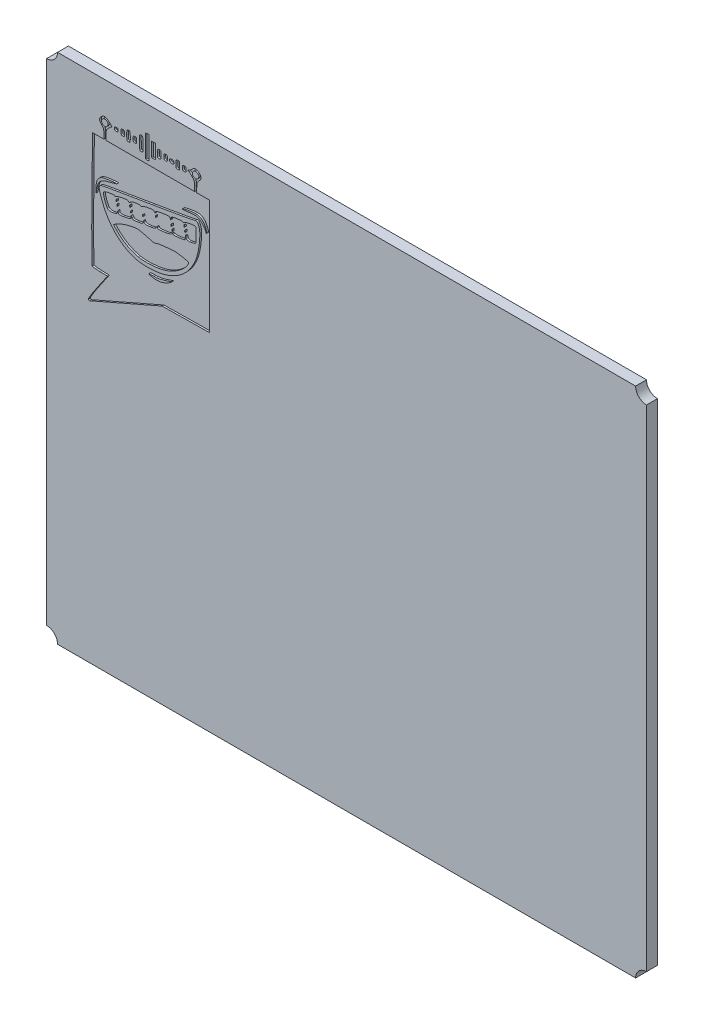
from build123d import *

# Parameters (mm, degrees)
ESQUISSE1_W             = 165
ESQUISSE1_H             = 141
BOSS_EXTRU_1_DEPTH      = 3
ESQUISSE2_R             = 3
ENL_V_MAT_EXTRU_1_DEPTH = 3
ENL_V_MAT_EXTRU_2_DEPTH = 0.5


with BuildPart() as part:
    # Esquisse1 → Boss.-Extru.1 (new body)
    with BuildSketch(Plane.XY):
        with Locations((82.5, 70.5)):
            Rectangle(ESQUISSE1_W, ESQUISSE1_H)
    extrude(amount=BOSS_EXTRU_1_DEPTH)

    # Esquisse2 → Enlèv. mat.-Extru.1 (cut)
    with BuildSketch(Plane.XY.offset(3)):
        with Locations((0, 141)):
            Circle(ESQUISSE2_R)
        with Locations((165, 141)):
            Circle(ESQUISSE2_R)
        with Locations((165, 0)):
            Circle(ESQUISSE2_R)
        Circle(ESQUISSE2_R)
    extrude(amount=-ENL_V_MAT_EXTRU_1_DEPTH, mode=Mode.SUBTRACT)

    # Esquisse4 → Enlèv. mat.-Extru.2 (cut)
    with BuildSketch(Plane(origin=(-49.029714864, 27.03507642, 3), x_dir=(1, 0, 0), z_dir=(0, 0, 1))):
        with BuildLine():
            Line((70.966404243, 63.607118888), (80.794741203, 67.905286568))
            Line((80.794741203, 67.905286568), (87.281438923, 68.003564248))
            Line((87.281438923, 68.003564248), (93.768141723, 68.101841928))
            Line((93.768141723, 68.101841928), (93.818464203, 83.876318888))
            Line((93.818464203, 83.876318888), (93.868771443, 99.650800928))
            Line((93.868771443, 99.650800928), (92.098503203, 99.650800928))
            Line((92.098503203, 99.650800928), (90.328229883, 99.650800928))
            Line((90.328229883, 99.650800928), (90.328229883, 100.913363808))
            add(Edge.make_bspline(
                [(90.328229883, 100.913363808), (90.328229883, 102.054123528), (90.385110643, 102.232817608), (90.917931523, 102.765628328)],
                knots=[0, 0, 0, 0, 1, 1, 1, 1], degree=3))
            add(Edge.make_bspline(
                [(90.917931523, 102.765628328), (91.633794963, 103.481496848), (91.664782963, 104.032549848), (91.025160163, 104.672187888)],
                knots=[0, 0, 0, 0, 1, 1, 1, 1], degree=3))
            add(Edge.make_bspline(
                [(91.025160163, 104.672187888), (90.366157163, 105.331190888), (89.632589923, 105.293248368), (88.952271243, 104.564974488)],
                knots=[0, 0, 0, 0, 1, 1, 1, 1], degree=3))
            add(Edge.make_bspline(
                [(88.952271243, 104.564974488), (88.649305123, 104.240636808), (88.304220723, 103.975272848), (88.185424923, 103.975272848)],
                knots=[0, 0, 0, 0, 1, 1, 1, 1], degree=3))
            add(Edge.make_bspline(
                [(88.185424923, 103.975272848), (88.066634203, 103.975272848), (87.969438563, 103.886809728), (87.969438563, 103.778707328)],
                knots=[0, 0, 0, 0, 1, 1, 1, 1], degree=3))
            add(Edge.make_bspline(
                [(87.969438563, 103.778707328), (87.969438563, 103.670589688), (88.063835123, 103.582141808), (88.179207003, 103.582141808)],
                knots=[0, 0, 0, 0, 1, 1, 1, 1], degree=3))
            add(Edge.make_bspline(
                [(88.179207003, 103.582141808), (88.294568723, 103.582141808), (88.692627363, 103.260176488), (89.063756923, 102.866659368)],
                knots=[0, 0, 0, 0, 1, 1, 1, 1], degree=3))
            add(Edge.make_bspline(
                [(89.063756923, 102.866659368), (89.686697003, 102.206152688), (89.738538403, 102.055129368), (89.738538403, 100.900994008)],
                knots=[0, 0, 0, 0, 1, 1, 1, 1], degree=3))
            Line((89.738538403, 100.900994008), (89.738538403, 99.650806008))
            Line((89.738538403, 99.650806008), (77.551405043, 99.650806008))
            Line((77.551405043, 99.650806008), (65.364271683, 99.650806008))
            Line((65.364271683, 99.650806008), (65.364271683, 100.900994008))
            add(Edge.make_bspline(
                [(65.364271683, 100.900994008), (65.364271683, 102.055129368), (65.416108003, 102.206152688), (66.039053163, 102.866659368)],
                knots=[0, 0, 0, 0, 1, 1, 1, 1], degree=3))
            add(Edge.make_bspline(
                [(66.039053163, 102.866659368), (66.410187803, 103.260176488), (66.818904283, 103.582141808), (66.947311443, 103.582141808)],
                knots=[0, 0, 0, 0, 1, 1, 1, 1], degree=3))
            add(Edge.make_bspline(
                [(66.947311443, 103.582141808), (67.075728763, 103.582141808), (66.816196643, 103.935958728), (66.370584123, 104.368408968)],
                knots=[0, 0, 0, 0, 1, 1, 1, 1], degree=3))
            add(Edge.make_bspline(
                [(66.370584123, 104.368408968), (65.421629963, 105.289336768), (64.779832923, 105.374365808), (64.077660083, 104.672192968)],
                knots=[0, 0, 0, 0, 1, 1, 1, 1], degree=3))
            add(Edge.make_bspline(
                [(64.077660083, 104.672192968), (63.438022043, 104.032554928), (63.469010043, 103.481496848), (64.184878563, 102.765633408)],
                knots=[0, 0, 0, 0, 1, 1, 1, 1], degree=3))
            add(Edge.make_bspline(
                [(64.184878563, 102.765633408), (64.717689283, 102.232822688), (64.774575123, 102.054128608), (64.774575123, 100.913368888)],
                knots=[0, 0, 0, 0, 1, 1, 1, 1], degree=3))
            Line((64.774575123, 100.913368888), (64.774575123, 99.650806008))
            Line((64.774575123, 99.650806008), (63.234054963, 99.650806008))
            Line((63.234054963, 99.650806008), (61.693524643, 99.650806008))
            Line((61.693524643, 99.650806008), (61.563496963, 91.247581768))
            add(Edge.make_bspline(
                [(61.563496963, 91.247581768), (61.389644123, 80.013491968), (61.403314403, 68.157965768), (61.590471763, 67.863488328)],
                knots=[0, 0, 0, 0, 1, 1, 1, 1], degree=3))
            add(Edge.make_bspline(
                [(61.590471763, 67.863488328), (61.688937403, 67.708528008), (62.449408323, 67.605353208), (63.763726243, 67.568634968)],
                knots=[0, 0, 0, 0, 1, 1, 1, 1], degree=3))
            Line((63.763726243, 67.568634968), (65.785505283, 67.512155528))
            Line((65.785505283, 67.512155528), (63.103615803, 63.612173488))
            add(Edge.make_bspline(
                [(63.103615803, 63.612173488), (61.440723523, 61.194002048), (60.465099363, 59.599171608), (60.535873923, 59.414737128)],
                knots=[0, 0, 0, 0, 1, 1, 1, 1], degree=3))
            add(Edge.make_bspline(
                [(60.535873923, 59.414737128), (60.598652563, 59.251135728), (60.759840963, 59.160412008), (60.894064723, 59.213127168)],
                knots=[0, 0, 0, 0, 1, 1, 1, 1], degree=3))
            add(Edge.make_bspline(
                [(60.894064723, 59.213127168), (61.028298643, 59.265827088), (65.560872763, 61.243135808), (70.966404243, 63.607118888)],
                knots=[0, 0, 0, 0, 1, 1, 1, 1], degree=3))
        make_face()
        with BuildLine():
            Line((62.636850163, 87.029225968), (62.661351003, 85.792855568))
            Line((62.661351003, 85.792855568), (62.806862523, 86.783287928))
            add(Edge.make_bspline(
                [(62.806862523, 86.783287928), (62.886903003, 87.328026488), (63.095228723, 88.049970688), (63.269833403, 88.387607808)],
                knots=[0, 0, 0, 0, 1, 1, 1, 1], degree=3))
            add(Edge.make_bspline(
                [(63.269833403, 88.387607808), (63.769095803, 89.353046568), (64.433636003, 89.741585288), (66.392174123, 90.213151528)],
                knots=[0, 0, 0, 0, 1, 1, 1, 1], degree=3))
            add(Edge.make_bspline(
                [(66.392174123, 90.213151528), (67.394437803, 90.454471848), (68.258698203, 90.697778448), (68.312754483, 90.753826088)],
                knots=[0, 0, 0, 0, 1, 1, 1, 1], degree=3))
            add(Edge.make_bspline(
                [(68.312754483, 90.753826088), (68.560602603, 91.010818208), (64.977378883, 90.537565408), (64.246438003, 90.216768488)],
                knots=[0, 0, 0, 0, 1, 1, 1, 1], degree=3))
            add(Edge.make_bspline(
                [(64.246438003, 90.216768488), (63.119323163, 89.722098408), (62.603682843, 88.700967608), (62.636850163, 87.029225968)],
                knots=[0, 0, 0, 0, 1, 1, 1, 1], degree=3))
        make_face(mode=Mode.SUBTRACT)
        with BuildLine():
            add(Edge.make_bspline(
                [(81.004768723, 73.602648808), (81.537924883, 73.763095528), (82.372187883, 74.170719808), (82.858689323, 74.508458528)],
                knots=[0, 0, 0, 0, 1, 1, 1, 1], degree=3))
            add(Edge.make_bspline(
                [(82.858689323, 74.508458528), (83.345190763, 74.846197248), (83.566328243, 75.057550648), (83.350108203, 74.978135008)],
                knots=[0, 0, 0, 0, 1, 1, 1, 1], degree=3))
            add(Edge.make_bspline(
                [(83.350108203, 74.978135008), (81.077712443, 74.143506248), (79.876724243, 73.870984568), (78.435939723, 73.863008968)],
                knots=[0, 0, 0, 0, 1, 1, 1, 1], degree=3))
            add(Edge.make_bspline(
                [(78.435939723, 73.863008968), (76.917583603, 73.854540608), (76.887108683, 73.845457568), (77.551389803, 73.597543408)],
                knots=[0, 0, 0, 0, 1, 1, 1, 1], degree=3))
            add(Edge.make_bspline(
                [(77.551389803, 73.597543408), (78.485119203, 73.249065568), (79.836673523, 73.251051848), (81.004768723, 73.602648808)],
                knots=[0, 0, 0, 0, 1, 1, 1, 1], degree=3))
        make_face(mode=Mode.SUBTRACT)
        with BuildLine():
            add(Edge.make_bspline(
                [(81.145952083, 75.652901248), (85.643372603, 76.820905008), (88.809071123, 79.785806368), (90.298232483, 84.224664648)],
                knots=[0, 0, 0, 0, 1, 1, 1, 1], degree=3))
            add(Edge.make_bspline(
                [(90.298232483, 84.224664648), (90.920883003, 86.080642648), (91.351905763, 89.685319208), (91.119246843, 91.090879008)],
                knots=[0, 0, 0, 0, 1, 1, 1, 1], degree=3))
            add(Edge.make_bspline(
                [(91.119246843, 91.090879008), (90.892998883, 92.457719048), (90.389311803, 93.116727128), (89.813534443, 92.799216968)],
                knots=[0, 0, 0, 0, 1, 1, 1, 1], degree=3))
            add(Edge.make_bspline(
                [(89.813534443, 92.799216968), (89.610116003, 92.687040408), (84.578650323, 91.783506528), (78.632510323, 90.791357128)],
                knots=[0, 0, 0, 0, 1, 1, 1, 1], degree=3))
            add(Edge.make_bspline(
                [(78.632510323, 90.791357128), (63.330849283, 88.238194848), (63.964000163, 88.358341928), (63.666444243, 87.951408528)],
                knots=[0, 0, 0, 0, 1, 1, 1, 1], degree=3))
            add(Edge.make_bspline(
                [(63.666444243, 87.951408528), (63.382878643, 87.563611488), (63.434598123, 87.211791008), (64.041536203, 85.399719448)],
                knots=[0, 0, 0, 0, 1, 1, 1, 1], degree=3))
            add(Edge.make_bspline(
                [(64.041536203, 85.399719448), (65.833490963, 80.049681888), (69.587011523, 76.321810248), (74.138986163, 75.371276208)],
                knots=[0, 0, 0, 0, 1, 1, 1, 1], degree=3))
            add(Edge.make_bspline(
                [(74.138986163, 75.371276208), (75.910854603, 75.001279488), (79.135984043, 75.130905848), (81.145952083, 75.652901248)],
                knots=[0, 0, 0, 0, 1, 1, 1, 1], degree=3))
        make_face(mode=Mode.SUBTRACT)
        with BuildLine():
            add(Edge.make_bspline(
                [(92.687011043, 92.672714808), (92.012564843, 94.065930208), (91.307775803, 94.540072008), (89.911263483, 94.540072008)],
                knots=[0, 0, 0, 0, 1, 1, 1, 1], degree=3))
            add(Edge.make_bspline(
                [(89.911263483, 94.540072008), (88.690488683, 94.540072008), (85.834512683, 93.922862168), (86.458453523, 93.793875888)],
                knots=[0, 0, 0, 0, 1, 1, 1, 1], degree=3))
            add(Edge.make_bspline(
                [(86.458453523, 93.793875888), (86.654480563, 93.753347648), (87.557318483, 93.818996488), (88.464758883, 93.939758248)],
                knots=[0, 0, 0, 0, 1, 1, 1, 1], degree=3))
            add(Edge.make_bspline(
                [(88.464758883, 93.939758248), (89.813443003, 94.119234648), (90.235524963, 94.108815568), (90.776702443, 93.882699688)],
                knots=[0, 0, 0, 0, 1, 1, 1, 1], degree=3))
            add(Edge.make_bspline(
                [(90.776702443, 93.882699688), (91.522974763, 93.570889288), (92.633213843, 92.333309848), (92.832085683, 91.591573968)],
                knots=[0, 0, 0, 0, 1, 1, 1, 1], degree=3))
            add(Edge.make_bspline(
                [(92.832085683, 91.591573968), (92.934503563, 91.209568128), (92.980198163, 91.177772408), (93.037302443, 91.448759928)],
                knots=[0, 0, 0, 0, 1, 1, 1, 1], degree=3))
            add(Edge.make_bspline(
                [(93.037302443, 91.448759928), (93.077718923, 91.640494368), (92.920071283, 92.191273048), (92.687011043, 92.672714808)],
                knots=[0, 0, 0, 0, 1, 1, 1, 1], degree=3))
        make_face(mode=Mode.SUBTRACT)
        with BuildLine():
            add(Edge.make_bspline(
                [(64.528845363, 103.008178008), (63.829136323, 103.415726088), (64.228185563, 104.564974488), (65.069403083, 104.564974488)],
                knots=[0, 0, 0, 0, 1, 1, 1, 1], degree=3))
            add(Edge.make_bspline(
                [(65.069403083, 104.564974488), (65.897178923, 104.564974488), (66.238778443, 103.698478888), (65.645063603, 103.104764048)],
                knots=[0, 0, 0, 0, 1, 1, 1, 1], degree=3))
            add(Edge.make_bspline(
                [(65.645063603, 103.104764048), (65.289702363, 102.749397728), (65.014097123, 102.725552208), (64.528845363, 103.008178008)],
                knots=[0, 0, 0, 0, 1, 1, 1, 1], degree=3))
        make_face(mode=Mode.SUBTRACT)
        with BuildLine():
            add(Edge.make_bspline(
                [(89.492813723, 103.008178008), (88.793104683, 103.415726088), (89.192153923, 104.564974488), (90.033376523, 104.564974488)],
                knots=[0, 0, 0, 0, 1, 1, 1, 1], degree=3))
            add(Edge.make_bspline(
                [(90.033376523, 104.564974488), (90.861147283, 104.564974488), (91.202746803, 103.698478888), (90.609031963, 103.104764048)],
                knots=[0, 0, 0, 0, 1, 1, 1, 1], degree=3))
            add(Edge.make_bspline(
                [(90.609031963, 103.104764048), (90.253670723, 102.749397728), (89.978065483, 102.725552208), (89.492813723, 103.008178008)],
                knots=[0, 0, 0, 0, 1, 1, 1, 1], degree=3))
        make_face(mode=Mode.SUBTRACT)
        with BuildLine():
            Line((68.312759563, 79.690607168), (67.428209643, 80.603808288))
            Line((67.428209643, 80.603808288), (67.919623443, 80.981475808))
            add(Edge.make_bspline(
                [(67.919623443, 80.981475808), (68.659586403, 81.550156408), (70.673654003, 82.309342088), (72.374229723, 82.660608848)],
                knots=[0, 0, 0, 0, 1, 1, 1, 1], degree=3))
            add(Edge.make_bspline(
                [(72.374229723, 82.660608848), (73.744544483, 82.943656288), (74.031671163, 82.944834848), (75.376438603, 82.672973568)],
                knots=[0, 0, 0, 0, 1, 1, 1, 1], degree=3))
            add(Edge.make_bspline(
                [(75.376438603, 82.672973568), (76.194272883, 82.507634808), (77.241713003, 82.238394808), (77.704074283, 82.074661328)],
                knots=[0, 0, 0, 0, 1, 1, 1, 1], degree=3))
            add(Edge.make_bspline(
                [(77.704074283, 82.074661328), (78.349320643, 81.846173088), (78.669172683, 81.826462688), (79.080043083, 81.989876128)],
                knots=[0, 0, 0, 0, 1, 1, 1, 1], degree=3))
            add(Edge.make_bspline(
                [(79.080043083, 81.989876128), (79.374464643, 82.106959968), (79.880706963, 82.237002888), (80.205044643, 82.278826528)],
                knots=[0, 0, 0, 0, 1, 1, 1, 1], degree=3))
            add(Edge.make_bspline(
                [(80.205044643, 82.278826528), (83.154685683, 82.659191528), (83.977955563, 82.723133488), (84.781906203, 82.634294448)],
                knots=[0, 0, 0, 0, 1, 1, 1, 1], degree=3))
            add(Edge.make_bspline(
                [(84.781906203, 82.634294448), (86.343930003, 82.461686208), (87.974991003, 82.109835248), (88.092201843, 81.920193768)],
                knots=[0, 0, 0, 0, 1, 1, 1, 1], degree=3))
            add(Edge.make_bspline(
                [(88.092201843, 81.920193768), (88.153385363, 81.821184568), (87.957043363, 81.384589048), (87.655880643, 80.950000128)],
                knots=[0, 0, 0, 0, 1, 1, 1, 1], degree=3))
            add(Edge.make_bspline(
                [(87.655880643, 80.950000128), (86.327008523, 79.032437288), (83.716863883, 77.353431248), (80.952094203, 76.637710048)],
                knots=[0, 0, 0, 0, 1, 1, 1, 1], degree=3))
            add(Edge.make_bspline(
                [(80.952094203, 76.637710048), (78.951945803, 76.119925968), (75.858672843, 75.981003208), (74.308038403, 76.339315928)],
                knots=[0, 0, 0, 0, 1, 1, 1, 1], degree=3))
            add(Edge.make_bspline(
                [(74.308038403, 76.339315928), (71.884441523, 76.899335128), (69.991537003, 77.957453408), (68.312759563, 79.690607168)],
                knots=[0, 0, 0, 0, 1, 1, 1, 1], degree=3))
        make_face()
        with BuildLine():
            Line((87.204400723, 87.567137008), (87.084858163, 86.786061608))
            Line((87.084858163, 86.786061608), (85.622473483, 86.542033648))
            add(Edge.make_bspline(
                [(85.622473483, 86.542033648), (84.545650643, 86.362338808), (84.090553763, 86.355704328), (83.896365683, 86.516872408)],
                knots=[0, 0, 0, 0, 1, 1, 1, 1], degree=3))
            add(Edge.make_bspline(
                [(83.896365683, 86.516872408), (83.698108523, 86.681413608), (83.573191323, 86.660326528), (83.393085003, 86.431909408)],
                knots=[0, 0, 0, 0, 1, 1, 1, 1], degree=3))
            add(Edge.make_bspline(
                [(83.393085003, 86.431909408), (83.261325043, 86.264807888), (82.571323883, 86.030543688), (81.859737803, 85.911331328)],
                knots=[0, 0, 0, 0, 1, 1, 1, 1], degree=3))
            add(Edge.make_bspline(
                [(81.859737803, 85.911331328), (80.002225643, 85.600120368), (79.517613963, 85.626409368), (79.514144323, 86.038575168)],
                knots=[0, 0, 0, 0, 1, 1, 1, 1], degree=3))
            add(Edge.make_bspline(
                [(79.514144323, 86.038575168), (79.512396803, 86.291792848), (79.446148523, 86.253896048), (79.264538523, 85.894978808)],
                knots=[0, 0, 0, 0, 1, 1, 1, 1], degree=3))
            add(Edge.make_bspline(
                [(79.264538523, 85.894978808), (79.058762963, 85.488274008), (78.790213843, 85.369569648), (77.645760963, 85.179399848)],
                knots=[0, 0, 0, 0, 1, 1, 1, 1], degree=3))
            add(Edge.make_bspline(
                [(77.645760963, 85.179399848), (76.211610923, 84.941091968), (75.804276203, 85.046898208), (75.759013403, 85.669508088)],
                knots=[0, 0, 0, 0, 1, 1, 1, 1], degree=3))
            add(Edge.make_bspline(
                [(75.759013403, 85.669508088), (75.746247363, 85.845464048), (75.679348843, 85.725997688), (75.610398003, 85.404006968)],
                knots=[0, 0, 0, 0, 1, 1, 1, 1], degree=3))
            add(Edge.make_bspline(
                [(75.610398003, 85.404006968), (75.492577563, 84.853776928), (75.404703723, 84.805400088), (74.148953123, 84.599426408)],
                knots=[0, 0, 0, 0, 1, 1, 1, 1], degree=3))
            add(Edge.make_bspline(
                [(74.148953123, 84.599426408), (72.890713323, 84.393041248), (72.796306603, 84.403927688), (72.528473763, 84.786314528)],
                knots=[0, 0, 0, 0, 1, 1, 1, 1], degree=3))
            Line((72.528473763, 84.786314528), (72.244069963, 85.192353848))
            Line((72.244069963, 85.192353848), (72.244069963, 84.759233048))
            add(Edge.make_bspline(
                [(72.244069963, 84.759233048), (72.244069963, 84.302205768), (72.271222563, 84.313529088), (70.232095323, 83.919869728)],
                knots=[0, 0, 0, 0, 1, 1, 1, 1], degree=3))
            add(Edge.make_bspline(
                [(70.232095323, 83.919869728), (68.973169723, 83.676832368), (68.716441763, 83.752961248), (68.682614043, 84.379355728)],
                knots=[0, 0, 0, 0, 1, 1, 1, 1], degree=3))
            add(Edge.make_bspline(
                [(68.682614043, 84.379355728), (68.665357283, 84.698725168), (68.626835643, 84.658049608), (68.533541443, 84.221977328)],
                knots=[0, 0, 0, 0, 1, 1, 1, 1], degree=3))
            add(Edge.make_bspline(
                [(68.533541443, 84.221977328), (68.437117963, 83.771325448), (68.270326323, 83.604523648), (67.819674443, 83.508110328)],
                knots=[0, 0, 0, 0, 1, 1, 1, 1], degree=3))
            add(Edge.make_bspline(
                [(67.819674443, 83.508110328), (66.575297963, 83.241872608), (65.974339043, 83.317823688), (65.683742723, 83.778056448)],
                knots=[0, 0, 0, 0, 1, 1, 1, 1], degree=3))
            add(Edge.make_bspline(
                [(65.683742723, 83.778056448), (65.104810683, 84.694976128), (64.501062843, 86.708073448), (64.707077163, 87.034671728)],
                knots=[0, 0, 0, 0, 1, 1, 1, 1], degree=3))
            add(Edge.make_bspline(
                [(64.707077163, 87.034671728), (64.950927323, 87.421254648), (67.522494443, 87.939434968), (67.803342243, 87.658582088)],
                knots=[0, 0, 0, 0, 1, 1, 1, 1], degree=3))
            add(Edge.make_bspline(
                [(67.803342243, 87.658582088), (67.925033643, 87.536900848), (68.102935243, 87.565272648), (68.300247523, 87.737799608)],
                knots=[0, 0, 0, 0, 1, 1, 1, 1], degree=3))
            add(Edge.make_bspline(
                [(68.300247523, 87.737799608), (68.469299763, 87.885617448), (69.223664523, 88.111438688), (69.976632283, 88.239632488)],
                knots=[0, 0, 0, 0, 1, 1, 1, 1], degree=3))
            add(Edge.make_bspline(
                [(69.976632283, 88.239632488), (71.148964203, 88.439225688), (71.376472003, 88.430569368), (71.560149563, 88.179363368)],
                knots=[0, 0, 0, 0, 1, 1, 1, 1], degree=3))
            add(Edge.make_bspline(
                [(71.560149563, 88.179363368), (71.747012283, 87.923819048), (71.803227563, 87.931794648), (71.996501243, 88.241273328)],
                knots=[0, 0, 0, 0, 1, 1, 1, 1], degree=3))
            add(Edge.make_bspline(
                [(71.996501243, 88.241273328), (72.261870283, 88.666189928), (74.571685323, 89.146031488), (74.877867083, 88.839849728)],
                knots=[0, 0, 0, 0, 1, 1, 1, 1], degree=3))
            add(Edge.make_bspline(
                [(74.877867083, 88.839849728), (75.002042603, 88.715669128), (75.178369403, 88.747149888), (75.379847283, 88.929486328)],
                knots=[0, 0, 0, 0, 1, 1, 1, 1], degree=3))
            add(Edge.make_bspline(
                [(75.379847283, 88.929486328), (75.550657203, 89.084070728), (76.305794123, 89.308850568), (77.057928763, 89.429007808)],
                knots=[0, 0, 0, 0, 1, 1, 1, 1], degree=3))
            add(Edge.make_bspline(
                [(77.057928763, 89.429007808), (78.256503963, 89.620478088), (78.454334403, 89.607966048), (78.659266683, 89.327702448)],
                knots=[0, 0, 0, 0, 1, 1, 1, 1], degree=3))
            add(Edge.make_bspline(
                [(78.659266683, 89.327702448), (78.872484443, 89.036115528), (78.899103643, 89.039168608), (78.961338723, 89.362337888)],
                knots=[0, 0, 0, 0, 1, 1, 1, 1], degree=3))
            add(Edge.make_bspline(
                [(78.961338723, 89.362337888), (79.015090203, 89.641392448), (79.405310403, 89.786172448), (80.796722403, 90.043276328)],
                knots=[0, 0, 0, 0, 1, 1, 1, 1], degree=3))
            add(Edge.make_bspline(
                [(80.796722403, 90.043276328), (82.621397443, 90.380441008), (83.030601603, 90.310088088), (83.078516163, 89.650978408)],
                knots=[0, 0, 0, 0, 1, 1, 1, 1], degree=3))
            add(Edge.make_bspline(
                [(83.078516163, 89.650978408), (83.091282203, 89.475017368), (83.158058803, 89.593772528), (83.226857243, 89.914894568)],
                knots=[0, 0, 0, 0, 1, 1, 1, 1], degree=3))
            add(Edge.make_bspline(
                [(83.226857243, 89.914894568), (83.345592083, 90.469081928), (83.426557123, 90.511230688), (84.821037443, 90.744712568)],
                knots=[0, 0, 0, 0, 1, 1, 1, 1], degree=3))
            add(Edge.make_bspline(
                [(84.821037443, 90.744712568), (85.757393203, 90.901486448), (86.358423243, 90.922405888), (86.478428083, 90.802401048)],
                knots=[0, 0, 0, 0, 1, 1, 1, 1], degree=3))
            add(Edge.make_bspline(
                [(86.478428083, 90.802401048), (86.598438003, 90.682386048), (86.778183643, 90.711362368), (86.974078603, 90.882263728)],
                knots=[0, 0, 0, 0, 1, 1, 1, 1], degree=3))
            add(Edge.make_bspline(
                [(86.974078603, 90.882263728), (87.406742203, 91.259758528), (89.762729363, 91.646016328), (90.026015603, 91.382618328)],
                knots=[0, 0, 0, 0, 1, 1, 1, 1], degree=3))
            add(Edge.make_bspline(
                [(90.026015603, 91.382618328), (90.268219843, 91.140312488), (90.235768803, 87.685704208), (89.988957003, 87.438907648)],
                knots=[0, 0, 0, 0, 1, 1, 1, 1], degree=3))
            add(Edge.make_bspline(
                [(89.988957003, 87.438907648), (89.896379083, 87.346314488), (89.382206883, 87.188656688), (88.846383723, 87.088550208)],
                knots=[0, 0, 0, 0, 1, 1, 1, 1], degree=3))
            add(Edge.make_bspline(
                [(88.846383723, 87.088550208), (87.728702443, 86.879746968), (87.394260643, 87.046050928), (87.351827403, 87.831718648)],
                knots=[0, 0, 0, 0, 1, 1, 1, 1], degree=3))
            add(Edge.make_bspline(
                [(87.351827403, 87.831718648), (87.332660563, 88.186505848), (87.286513843, 88.103666288), (87.204400723, 87.567137008)],
                knots=[0, 0, 0, 0, 1, 1, 1, 1], degree=3))
        make_face()
        with BuildLine():
            add(Edge.make_bspline(
                [(68.442939643, 85.940277168), (68.388385523, 86.075420408), (68.343803443, 85.964833888), (68.343803443, 85.694567728)],
                knots=[0, 0, 0, 0, 1, 1, 1, 1], degree=3))
            add(Edge.make_bspline(
                [(68.343803443, 85.694567728), (68.343803443, 85.424291408), (68.388410923, 85.313720128), (68.442939643, 85.448863368)],
                knots=[0, 0, 0, 0, 1, 1, 1, 1], degree=3))
            add(Edge.make_bspline(
                [(68.442939643, 85.448863368), (68.497498843, 85.584006608), (68.497498843, 85.805139008), (68.442939643, 85.940277168)],
                knots=[0, 0, 0, 0, 1, 1, 1, 1], degree=3))
        make_face(mode=Mode.SUBTRACT)
        with BuildLine():
            add(Edge.make_bspline(
                [(72.181763763, 86.124559248), (72.119051163, 86.281368688), (72.072462483, 86.234805408), (72.063054323, 86.005799008)],
                knots=[0, 0, 0, 0, 1, 1, 1, 1], degree=3))
            add(Edge.make_bspline(
                [(72.063054323, 86.005799008), (72.054453883, 85.798585808), (72.100961283, 85.682487488), (72.166295163, 85.747801048)],
                knots=[0, 0, 0, 0, 1, 1, 1, 1], degree=3))
            add(Edge.make_bspline(
                [(72.166295163, 85.747801048), (72.231603643, 85.813109528), (72.238593723, 85.982664688), (72.181763763, 86.124559248)],
                knots=[0, 0, 0, 0, 1, 1, 1, 1], degree=3))
        make_face(mode=Mode.SUBTRACT)
        with BuildLine():
            add(Edge.make_bspline(
                [(68.250427963, 86.910821328), (68.187715363, 87.067635848), (68.141126683, 87.021067488), (68.131718523, 86.792061088)],
                knots=[0, 0, 0, 0, 1, 1, 1, 1], degree=3))
            add(Edge.make_bspline(
                [(68.131718523, 86.792061088), (68.123118083, 86.584852968), (68.169620403, 86.468749568), (68.234959363, 86.534068208)],
                knots=[0, 0, 0, 0, 1, 1, 1, 1], degree=3))
            add(Edge.make_bspline(
                [(68.234959363, 86.534068208), (68.300267843, 86.599376688), (68.307257923, 86.768926768), (68.250427963, 86.910821328)],
                knots=[0, 0, 0, 0, 1, 1, 1, 1], degree=3))
        make_face(mode=Mode.SUBTRACT)
        with BuildLine():
            add(Edge.make_bspline(
                [(75.523392843, 86.910821328), (75.460680243, 87.067635848), (75.414091563, 87.021067488), (75.404683403, 86.792061088)],
                knots=[0, 0, 0, 0, 1, 1, 1, 1], degree=3))
            add(Edge.make_bspline(
                [(75.404683403, 86.792061088), (75.396082963, 86.584852968), (75.442590363, 86.468749568), (75.507924243, 86.534068208)],
                knots=[0, 0, 0, 0, 1, 1, 1, 1], degree=3))
            add(Edge.make_bspline(
                [(75.507924243, 86.534068208), (75.573232723, 86.599376688), (75.580222803, 86.768926768), (75.523392843, 86.910821328)],
                knots=[0, 0, 0, 0, 1, 1, 1, 1], degree=3))
        make_face(mode=Mode.SUBTRACT)
        with BuildLine():
            add(Edge.make_bspline(
                [(71.981139323, 87.512811488), (71.926585203, 87.647954728), (71.881998043, 87.537368208), (71.881998043, 87.267102048)],
                knots=[0, 0, 0, 0, 1, 1, 1, 1], degree=3))
            add(Edge.make_bspline(
                [(71.881998043, 87.267102048), (71.881998043, 86.996820648), (71.926610603, 86.886254448), (71.981139323, 87.021397688)],
                knots=[0, 0, 0, 0, 1, 1, 1, 1], degree=3))
            add(Edge.make_bspline(
                [(71.981139323, 87.021397688), (72.035693443, 87.156535848), (72.035693443, 87.377673328), (71.981139323, 87.512811488)],
                knots=[0, 0, 0, 0, 1, 1, 1, 1], degree=3))
        make_face(mode=Mode.SUBTRACT)
        with BuildLine():
            add(Edge.make_bspline(
                [(83.578571043, 87.512811488), (83.524016923, 87.647954728), (83.479429763, 87.537368208), (83.479429763, 87.267102048)],
                knots=[0, 0, 0, 0, 1, 1, 1, 1], degree=3))
            add(Edge.make_bspline(
                [(83.479429763, 87.267102048), (83.479429763, 86.996820648), (83.524027083, 86.886254448), (83.578571043, 87.021397688)],
                knots=[0, 0, 0, 0, 1, 1, 1, 1], degree=3))
            add(Edge.make_bspline(
                [(83.578571043, 87.021397688), (83.633130243, 87.156535848), (83.633130243, 87.377673328), (83.578571043, 87.512811488)],
                knots=[0, 0, 0, 0, 1, 1, 1, 1], degree=3))
        make_face(mode=Mode.SUBTRACT)
        with BuildLine():
            add(Edge.make_bspline(
                [(79.061597603, 88.483355648), (78.998879923, 88.640170168), (78.952296323, 88.593601808), (78.942888163, 88.364595408)],
                knots=[0, 0, 0, 0, 1, 1, 1, 1], degree=3))
            add(Edge.make_bspline(
                [(78.942888163, 88.364595408), (78.934282643, 88.157387288), (78.980805283, 88.041288968), (79.046123923, 88.106602528)],
                knots=[0, 0, 0, 0, 1, 1, 1, 1], degree=3))
            add(Edge.make_bspline(
                [(79.046123923, 88.106602528), (79.111432403, 88.171911008), (79.118422483, 88.341461088), (79.061597603, 88.483355648)],
                knots=[0, 0, 0, 0, 1, 1, 1, 1], degree=3))
        make_face(mode=Mode.SUBTRACT)
        with BuildLine():
            add(Edge.make_bspline(
                [(83.382005523, 88.692209688), (83.327451403, 88.827358008), (83.282869323, 88.716796888), (83.282869323, 88.446505328)],
                knots=[0, 0, 0, 0, 1, 1, 1, 1], degree=3))
            add(Edge.make_bspline(
                [(83.282869323, 88.446505328), (83.282869323, 88.176223928), (83.327461563, 88.065657728), (83.382005523, 88.200795888)],
                knots=[0, 0, 0, 0, 1, 1, 1, 1], degree=3))
            add(Edge.make_bspline(
                [(83.382005523, 88.200795888), (83.436564723, 88.335939128), (83.436564723, 88.557071528), (83.382005523, 88.692209688)],
                knots=[0, 0, 0, 0, 1, 1, 1, 1], degree=3))
        make_face(mode=Mode.SUBTRACT)
        with BuildLine():
            add(Edge.make_bspline(
                [(87.116770723, 89.085345808), (87.062216603, 89.220489048), (87.017619283, 89.109917768), (87.017619283, 88.839636368)],
                knots=[0, 0, 0, 0, 1, 1, 1, 1], degree=3))
            add(Edge.make_bspline(
                [(87.017619283, 88.839636368), (87.017619283, 88.569354968), (87.062216603, 88.458788768), (87.116770723, 88.593932008)],
                knots=[0, 0, 0, 0, 1, 1, 1, 1], degree=3))
            add(Edge.make_bspline(
                [(87.116770723, 88.593932008), (87.171329923, 88.729070168), (87.171329923, 88.950202568), (87.116770723, 89.085345808)],
                knots=[0, 0, 0, 0, 1, 1, 1, 1], degree=3))
        make_face(mode=Mode.SUBTRACT)
        with BuildLine():
            add(Edge.make_bspline(
                [(86.920205203, 90.264744008), (86.865651083, 90.399887248), (86.821069003, 90.289315968), (86.821069003, 90.019039648)],
                knots=[0, 0, 0, 0, 1, 1, 1, 1], degree=3))
            add(Edge.make_bspline(
                [(86.821069003, 90.019039648), (86.821069003, 89.748758248), (86.865676483, 89.638192048), (86.920205203, 89.773330208)],
                knots=[0, 0, 0, 0, 1, 1, 1, 1], degree=3))
            add(Edge.make_bspline(
                [(86.920205203, 89.773330208), (86.974764403, 89.908473448), (86.974764403, 90.129605848), (86.920205203, 90.264744008)],
                knots=[0, 0, 0, 0, 1, 1, 1, 1], degree=3))
        make_face(mode=Mode.SUBTRACT)
        Polygon((77.158253683, 103.778707328), (77.158253683, 106.923775968), (76.666839883, 106.923775968), (76.175421003, 106.923775968), (76.175421003, 103.778707328), (76.175421003, 100.633638688), (76.666839883, 100.633638688), (77.158253683, 100.633638688), align=None)
        Polygon((78.927353523, 103.778707328), (78.927353523, 105.744372688), (78.435939723, 105.744372688), (77.944520843, 105.744372688), (77.944520843, 103.778707328), (77.944520843, 101.813036888), (78.435939723, 101.813036888), (78.927353523, 101.813036888), align=None)
        with BuildLine():
            add(Edge.make_bspline(
                [(75.585724443, 103.686591688), (75.585724443, 105.170642568), (75.524419003, 105.583666888), (75.290871083, 105.673288248)],
                knots=[0, 0, 0, 0, 1, 1, 1, 1], degree=3))
            add(Edge.make_bspline(
                [(75.290871083, 105.673288248), (74.608241003, 105.935243528), (74.502947843, 105.648970288), (74.567235243, 103.705941408)],
                knots=[0, 0, 0, 0, 1, 1, 1, 1], degree=3))
            add(Edge.make_bspline(
                [(74.567235243, 103.705941408), (74.628662603, 101.849308088), (74.639025803, 101.813041968), (75.107792963, 101.813041968)],
                knots=[0, 0, 0, 0, 1, 1, 1, 1], degree=3))
            add(Edge.make_bspline(
                [(75.107792963, 101.813041968), (75.580563163, 101.813041968), (75.585724443, 101.833280688), (75.585724443, 103.686591688)],
                knots=[0, 0, 0, 0, 1, 1, 1, 1], degree=3))
        make_face()
        with BuildLine():
            add(Edge.make_bspline(
                [(72.047519683, 103.778707328), (72.047519683, 105.115362008), (72.033488723, 105.154676128), (71.556105883, 105.154676128)],
                knots=[0, 0, 0, 0, 1, 1, 1, 1], degree=3))
            add(Edge.make_bspline(
                [(71.556105883, 105.154676128), (71.078728123, 105.154676128), (71.064687003, 105.115351848), (71.064687003, 103.778707328)],
                knots=[0, 0, 0, 0, 1, 1, 1, 1], degree=3))
            add(Edge.make_bspline(
                [(71.064687003, 103.778707328), (71.064687003, 102.442052648), (71.078717963, 102.402738528), (71.556105883, 102.402738528)],
                knots=[0, 0, 0, 0, 1, 1, 1, 1], degree=3))
            add(Edge.make_bspline(
                [(71.556105883, 102.402738528), (72.033478563, 102.402738528), (72.047519683, 102.442067888), (72.047519683, 103.778707328)],
                knots=[0, 0, 0, 0, 1, 1, 1, 1], degree=3))
        make_face()
        with BuildLine():
            add(Edge.make_bspline(
                [(80.499887843, 103.680424568), (80.499887843, 104.702571368), (80.473116243, 104.761540008), (80.008468963, 104.761540008)],
                knots=[0, 0, 0, 0, 1, 1, 1, 1], degree=3))
            add(Edge.make_bspline(
                [(80.008468963, 104.761540008), (79.543862323, 104.761540008), (79.517055163, 104.702566288), (79.517055163, 103.680424568)],
                knots=[0, 0, 0, 0, 1, 1, 1, 1], degree=3))
            add(Edge.make_bspline(
                [(79.517055163, 103.680424568), (79.517055163, 102.658277768), (79.543831843, 102.599309128), (80.008468963, 102.599309128)],
                knots=[0, 0, 0, 0, 1, 1, 1, 1], degree=3))
            add(Edge.make_bspline(
                [(80.008468963, 102.599309128), (80.473090843, 102.599309128), (80.499887843, 102.658282848), (80.499887843, 103.680424568)],
                knots=[0, 0, 0, 0, 1, 1, 1, 1], degree=3))
        make_face()
        with BuildLine():
            add(Edge.make_bspline(
                [(85.610621843, 103.680424568), (85.610621843, 104.702571368), (85.583850243, 104.761540008), (85.119208043, 104.761540008)],
                knots=[0, 0, 0, 0, 1, 1, 1, 1], degree=3))
            add(Edge.make_bspline(
                [(85.119208043, 104.761540008), (84.654596323, 104.761540008), (84.627789163, 104.702566288), (84.627789163, 103.680424568)],
                knots=[0, 0, 0, 0, 1, 1, 1, 1], degree=3))
            add(Edge.make_bspline(
                [(84.627789163, 103.680424568), (84.627789163, 102.658277768), (84.654565843, 102.599309128), (85.119208043, 102.599309128)],
                knots=[0, 0, 0, 0, 1, 1, 1, 1], degree=3))
            add(Edge.make_bspline(
                [(85.119208043, 102.599309128), (85.583824843, 102.599309128), (85.610621843, 102.658282848), (85.610621843, 103.680424568)],
                knots=[0, 0, 0, 0, 1, 1, 1, 1], degree=3))
        make_face()
        with BuildLine():
            add(Edge.make_bspline(
                [(70.474990443, 103.778707328), (70.474990443, 104.486346248), (70.425851603, 104.564974488), (69.983571563, 104.564974488)],
                knots=[0, 0, 0, 0, 1, 1, 1, 1], degree=3))
            add(Edge.make_bspline(
                [(69.983571563, 104.564974488), (69.541296603, 104.564974488), (69.492152683, 104.486346248), (69.492152683, 103.778707328)],
                knots=[0, 0, 0, 0, 1, 1, 1, 1], degree=3))
            add(Edge.make_bspline(
                [(69.492152683, 103.778707328), (69.492152683, 103.071068408), (69.541296603, 102.992440168), (69.983571563, 102.992440168)],
                knots=[0, 0, 0, 0, 1, 1, 1, 1], degree=3))
            add(Edge.make_bspline(
                [(69.983571563, 102.992440168), (70.425846523, 102.992440168), (70.474990443, 103.071068408), (70.474990443, 103.778707328)],
                knots=[0, 0, 0, 0, 1, 1, 1, 1], degree=3))
        make_face()
        with BuildLine():
            add(Edge.make_bspline(
                [(73.816624603, 103.778707328), (73.816624603, 104.486346248), (73.767480683, 104.564974488), (73.325205723, 104.564974488)],
                knots=[0, 0, 0, 0, 1, 1, 1, 1], degree=3))
            add(Edge.make_bspline(
                [(73.325205723, 104.564974488), (72.882930763, 104.564974488), (72.833791923, 104.486346248), (72.833791923, 103.778707328)],
                knots=[0, 0, 0, 0, 1, 1, 1, 1], degree=3))
            add(Edge.make_bspline(
                [(72.833791923, 103.778707328), (72.833791923, 103.071068408), (72.882930763, 102.992440168), (73.325205723, 102.992440168)],
                knots=[0, 0, 0, 0, 1, 1, 1, 1], degree=3))
            add(Edge.make_bspline(
                [(73.325205723, 102.992440168), (73.767480683, 102.992440168), (73.816624603, 103.071068408), (73.816624603, 103.778707328)],
                knots=[0, 0, 0, 0, 1, 1, 1, 1], degree=3))
        make_face()
        with BuildLine():
            add(Edge.make_bspline(
                [(82.268987683, 103.778707328), (82.268987683, 104.486346248), (82.219848843, 104.564974488), (81.777573883, 104.564974488)],
                knots=[0, 0, 0, 0, 1, 1, 1, 1], degree=3))
            add(Edge.make_bspline(
                [(81.777573883, 104.564974488), (81.335298923, 104.564974488), (81.286155003, 104.486346248), (81.286155003, 103.778707328)],
                knots=[0, 0, 0, 0, 1, 1, 1, 1], degree=3))
            add(Edge.make_bspline(
                [(81.286155003, 103.778707328), (81.286155003, 103.071068408), (81.335293843, 102.992440168), (81.777573883, 102.992440168)],
                knots=[0, 0, 0, 0, 1, 1, 1, 1], degree=3))
            add(Edge.make_bspline(
                [(81.777573883, 102.992440168), (82.219848843, 102.992440168), (82.268987683, 103.071068408), (82.268987683, 103.778707328)],
                knots=[0, 0, 0, 0, 1, 1, 1, 1], degree=3))
        make_face()
        with BuildLine():
            add(Edge.make_bspline(
                [(87.379721683, 103.680424568), (87.379721683, 104.283227528), (87.318919163, 104.368408968), (86.888307883, 104.368408968)],
                knots=[0, 0, 0, 0, 1, 1, 1, 1], degree=3))
            add(Edge.make_bspline(
                [(86.888307883, 104.368408968), (86.457732163, 104.368408968), (86.396889003, 104.283222448), (86.396889003, 103.680424568)],
                knots=[0, 0, 0, 0, 1, 1, 1, 1], degree=3))
            add(Edge.make_bspline(
                [(86.396889003, 103.680424568), (86.396889003, 103.077616528), (86.457762643, 102.992440168), (86.888307883, 102.992440168)],
                knots=[0, 0, 0, 0, 1, 1, 1, 1], degree=3))
            add(Edge.make_bspline(
                [(86.888307883, 102.992440168), (87.318888683, 102.992440168), (87.379721683, 103.077631768), (87.379721683, 103.680424568)],
                knots=[0, 0, 0, 0, 1, 1, 1, 1], degree=3))
        make_face()
        with BuildLine():
            add(Edge.make_bspline(
                [(68.705890603, 103.680424568), (68.705890603, 104.073555608), (68.607607843, 104.171838368), (68.214471723, 104.171838368)],
                knots=[0, 0, 0, 0, 1, 1, 1, 1], degree=3))
            add(Edge.make_bspline(
                [(68.214471723, 104.171838368), (67.821340683, 104.171838368), (67.723057923, 104.073555608), (67.723057923, 103.680424568)],
                knots=[0, 0, 0, 0, 1, 1, 1, 1], degree=3))
            add(Edge.make_bspline(
                [(67.723057923, 103.680424568), (67.723057923, 103.287288448), (67.821335603, 103.189005688), (68.214471723, 103.189005688)],
                knots=[0, 0, 0, 0, 1, 1, 1, 1], degree=3))
            add(Edge.make_bspline(
                [(68.214471723, 103.189005688), (68.607602763, 103.189005688), (68.705890603, 103.287288448), (68.705890603, 103.680424568)],
                knots=[0, 0, 0, 0, 1, 1, 1, 1], degree=3))
        make_face()
        with BuildLine():
            add(Edge.make_bspline(
                [(84.038092603, 103.680424568), (84.038092603, 104.095399608), (83.946357963, 104.171838368), (83.448390963, 104.171838368)],
                knots=[0, 0, 0, 0, 1, 1, 1, 1], degree=3))
            add(Edge.make_bspline(
                [(83.448390963, 104.171838368), (83.007609523, 104.171838368), (82.858689323, 104.080830168), (82.858689323, 103.811468248)],
                knots=[0, 0, 0, 0, 1, 1, 1, 1], degree=3))
            add(Edge.make_bspline(
                [(82.858689323, 103.811468248), (82.858689323, 103.334100648), (83.026700163, 103.189005688), (83.579439723, 103.189005688)],
                knots=[0, 0, 0, 0, 1, 1, 1, 1], degree=3))
            add(Edge.make_bspline(
                [(83.579439723, 103.189005688), (83.937625443, 103.189005688), (84.038092603, 103.296655968), (84.038092603, 103.680424568)],
                knots=[0, 0, 0, 0, 1, 1, 1, 1], degree=3))
        make_face()
    extrude(amount=-ENL_V_MAT_EXTRU_2_DEPTH, mode=Mode.SUBTRACT)


solid = part.part
